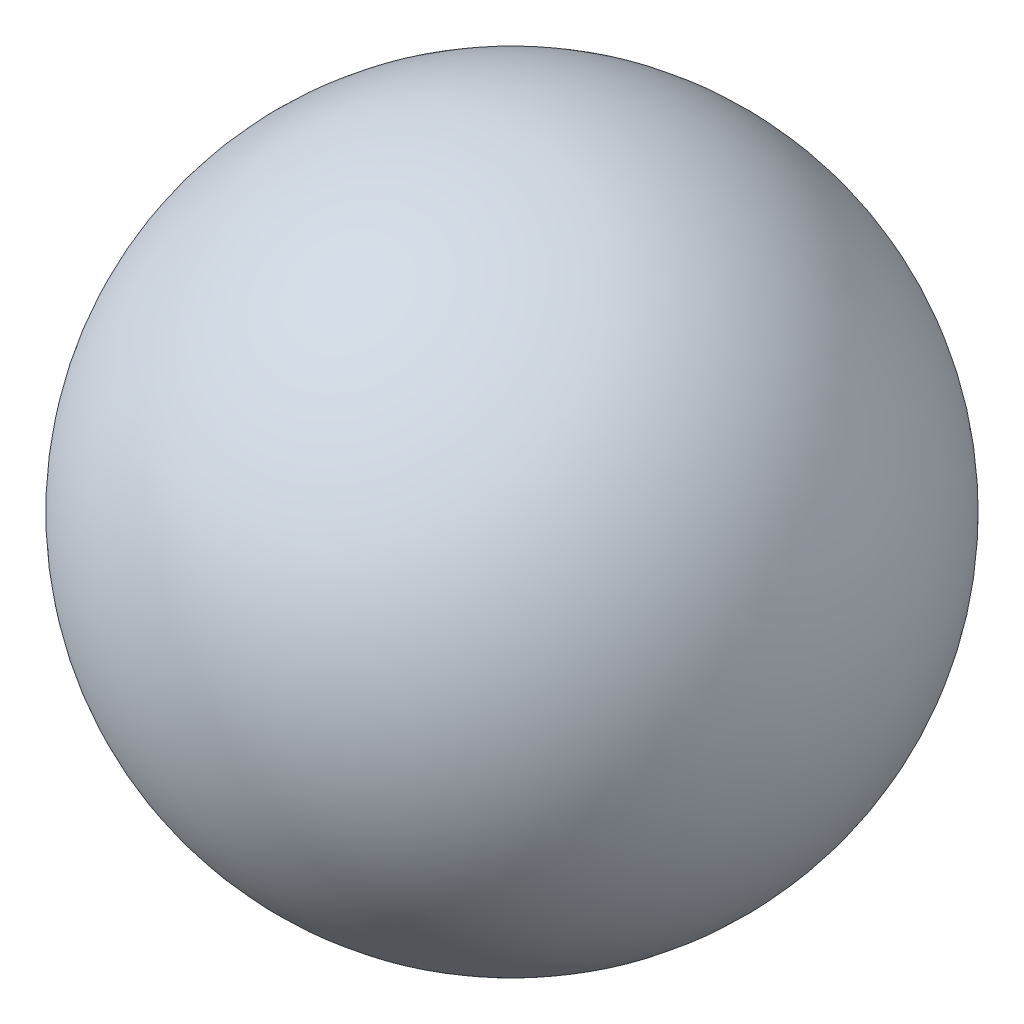
from build123d import *


with BuildPart() as part:
    # Sketch1 → Revolve3 (revolve)
    with BuildSketch(Plane.XY):
        with BuildLine():
            Line((0, 0), (0, 76))
            ThreePointArc((0, 76), (-76, 0), (0, -76))
            Line((0, -76), (0, 0))
        make_face()
    revolve(axis=Axis((0, 0, 0), (0, 1, 0)))


solid = part.part
